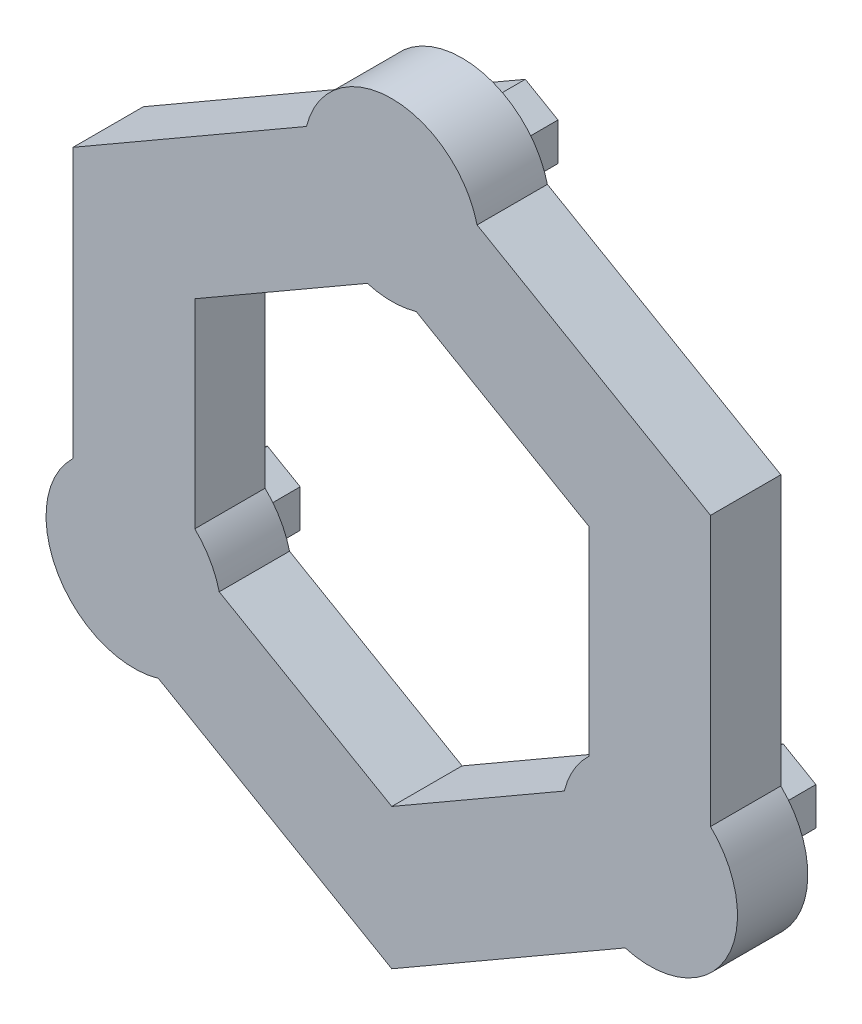
from build123d import *

# Parameters (mm, degrees)
SKETCH3_R           = 12.5
BOSS_EXTRUDE2_DEPTH = 5
BOSS_EXTRUDE3_DEPTH = 9


with BuildPart() as part:
    # Sketch3 → Boss-Extrude2 (new, symmetric)
    # profile 1 of 4: a face of its own
    with BuildSketch(Plane.XY):
        with Locations((-36.682238028, -21.1785)):
            Circle(SKETCH3_R)
    # profile 2 of 4: a face of its own
    with BuildSketch(Plane.XY):
        with Locations((36.682238028, -21.1785)):
            Circle(SKETCH3_R)
    # profile 3 of 4: a face of its own
    with BuildSketch(Plane.XY):
        with Locations((0, 42.357)):
            Circle(SKETCH3_R)
    # profile 4 of 4: a face of its own
    with BuildSketch(Plane.XY):
        Polygon((0, 52.357), (-45.342492066, 26.1785), (-45.342492066, -26.1785), (0, -52.357), (45.342492066, -26.1785), (45.342492066, 26.1785), align=None)
        Polygon((0, 32.357), (-28.02198399, 16.1785), (-28.02198399, -16.1785), (0, -32.357), (28.02198399, -16.1785), (28.02198399, 16.1785), align=None, mode=Mode.SUBTRACT)
    extrude(amount=BOSS_EXTRUDE2_DEPTH, both=True)

    # Sketch4 → Boss-Extrude3 (add)
    with BuildSketch(Plane(origin=(0, 0, -5), x_dir=(-1, 0, 0), z_dir=(0, 0, -1))):
        Polygon((-41.332238028, -23.863178752), (-36.682238028, -26.547857503), (-32.032238028, -23.863178752), (-32.032238028, -18.493821248), (-36.682238028, -15.809142497), (-41.332238028, -18.493821248), align=None)
        Polygon((41.332238028, -23.863178752), (41.332238028, -18.493821248), (36.682238028, -15.809142497), (32.032238028, -18.493821248), (32.032238028, -23.863178752), (36.682238028, -26.547857503), align=None)
        Polygon((0, 47.726357503), (-4.65, 45.041678752), (-4.65, 39.672321248), (0, 36.987642497), (4.65, 39.672321248), (4.65, 45.041678752), align=None)
    extrude(amount=BOSS_EXTRUDE3_DEPTH)


solid = part.part
